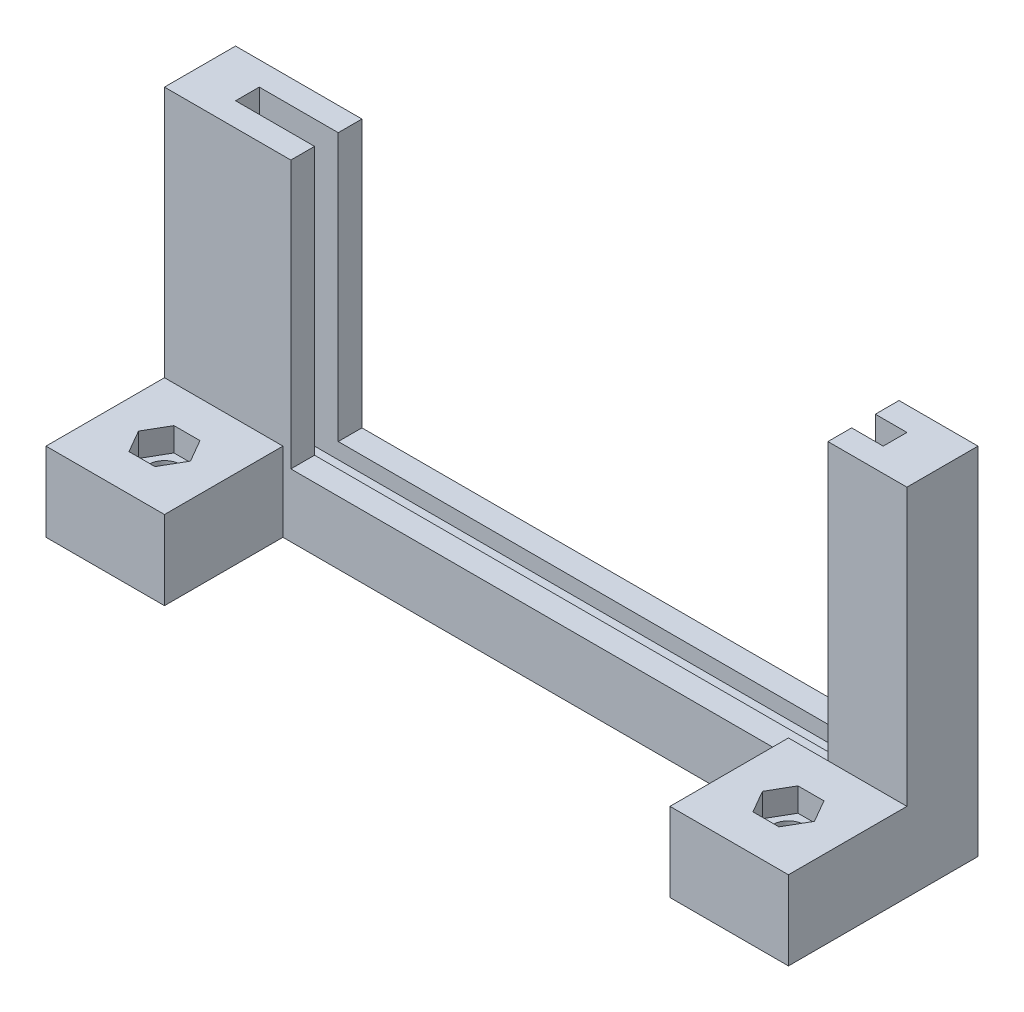
from build123d import *

# Parameters (mm, degrees)
BOSS_EXTRU_1_DEPTH      = 3
BOSS_EXTRU_2_DEPTH      = 1.5
ESQUISSE3_W             = 15
ESQUISSE3_H             = 15
BOSS_EXTRU_3_DEPTH      = 10
ESQUISSE4_R             = 2
ENL_V_MAT_EXTRU_1_DEPTH = 10
ENL_V_MAT_EXTRU_2_DEPTH = 3


with BuildPart() as part:
    # Esquisse1 → Boss.-Extru.1 (new body)
    with BuildSketch(Plane.XY):
        Polygon((26.306445504, -26.841854987), (-41.693554496, -26.841854987), (-41.693554496, 7.023864035), (-57.693554496, 7.023864035), (-57.693554496, -34.841854987), (-41.693554496, -34.841854987), (26.306445504, -34.841854987), (36.306445504, -34.841854987), (36.306445504, 10.158145013), (26.306445504, 10.158145013), align=None)
    extrude(amount=BOSS_EXTRU_1_DEPTH)

    # Esquisse2 → Boss.-Extru.2 (add)
    with BuildSketch(Plane.XY.offset(3)):
        Polygon((-57.693554496, 7.023864035), (-57.693554496, -34.841854987), (36.306445504, -34.841854987), (36.306445504, 10.158145013), (30.306445504, 10.158145013), (30.306445504, -28.841854987), (-51.693554496, -28.841854987), (-51.693554496, 7.023864035), align=None)
    extrude(amount=BOSS_EXTRU_2_DEPTH)

    # Symétrie3: part across plane


with BuildPart() as part_1:
    add(part.part)
    add(part.part.mirror(Plane.XY.offset(4.5)))

    # Esquisse3 → Boss.-Extru.3 (add)
    with BuildSketch(Plane.XZ.offset(34.841854987)):
        with Locations((-50.193554496, 16.5)):
            Rectangle(ESQUISSE3_W, ESQUISSE3_H)
        with Locations((28.806445504, 16.5)):
            Rectangle(ESQUISSE3_W, ESQUISSE3_H)
    extrude(amount=-BOSS_EXTRU_3_DEPTH)

    # Esquisse4 → Enlèv. mat.-Extru.1 (cut)
    with BuildSketch(Plane(origin=(0, -24.841854987, 0), x_dir=(1, 0, 0), z_dir=(0, 1, 0))):
        with Locations((-50.193554496, -16.5)):
            Circle(ESQUISSE4_R)
        with Locations((28.806445504, -16.5)):
            Circle(ESQUISSE4_R)
    extrude(amount=-ENL_V_MAT_EXTRU_1_DEPTH, mode=Mode.SUBTRACT)

    # Esquisse5 → Enlèv. mat.-Extru.2 (cut)
    with BuildSketch(Plane(origin=(0, -24.841854987, 0), x_dir=(1, 0, 0), z_dir=(0, 1, 0))):
        Polygon((-51.839002763, -13.65), (-48.548106229, -13.65), (-46.902657962, -16.5), (-48.548106229, -19.35), (-51.839002763, -19.35), (-53.484451031, -16.5), align=None)
        Polygon((27.160997237, -13.65), (30.451893771, -13.65), (32.097342038, -16.5), (30.451893771, -19.35), (27.160997237, -19.35), (25.515548969, -16.5), align=None)
    extrude(amount=-ENL_V_MAT_EXTRU_2_DEPTH, mode=Mode.SUBTRACT)


solid = part_1.part
